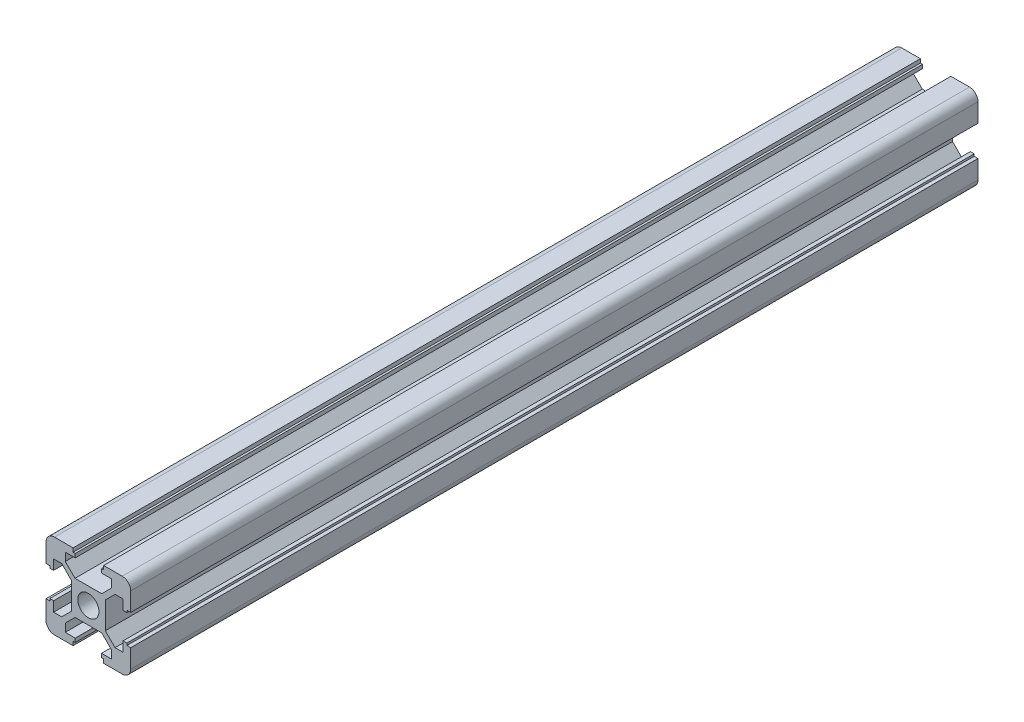
from build123d import *

# Parameters (mm, degrees)
SKETCH_1_R      = 2.5
EXTRUDE_1_DEPTH = 200
FILLET_1_R      = 2


with BuildPart() as part:
    # 草图1 → 凸台-拉伸1 (new body)
    with BuildSketch(Plane.XY):
        Polygon((-3.151471863, 4), (3.151471863, 4), (5.45, 6.298528137), (5.45, 8.2), (3.1, 8.2), (3.1, 9.1), (3.6, 9.1), (3.6, 10), (10, 10), (10, 3.6), (9.1, 3.6), (9.1, 3.1), (8.2, 3.1), (8.2, 5.45), (6.298528137, 5.45), (4, 3.151471863), (4, -3.151471863), (6.298528137, -5.45), (8.2, -5.45), (8.2, -3.1), (9.1, -3.1), (9.1, -3.6), (10, -3.6), (10, -10), (3.6, -10), (3.6, -9.1), (3.1, -9.1), (3.1, -8.2), (5.45, -8.2), (5.45, -6.298528137), (3.151471863, -4), (-3.151471863, -4), (-5.45, -6.298528137), (-5.45, -8.2), (-3.1, -8.2), (-3.1, -9.1), (-3.6, -9.1), (-3.6, -10), (-10, -10), (-10, -3.6), (-9.1, -3.6), (-9.1, -3.1), (-8.2, -3.1), (-8.2, -5.45), (-6.298528137, -5.45), (-4, -3.151471863), (-4, 3.151471863), (-6.298528137, 5.45), (-8.2, 5.45), (-8.2, 3.1), (-9.1, 3.1), (-9.1, 3.6), (-10, 3.6), (-10, 10), (-3.6, 10), (-3.6, 9.1), (-3.1, 9.1), (-3.1, 8.2), (-5.45, 8.2), (-5.45, 6.298528137), align=None)
        Circle(SKETCH_1_R, mode=Mode.SUBTRACT)
    extrude(amount=EXTRUDE_1_DEPTH)

    # 圆角1
    fillet_1_edges = [part.edges().sort_by_distance(p)[0] for p in [
        (10, -10, 100),
        (-10, -10, 100),
        (-10, 10, 100),
        (10, 10, 100),
    ]]
    fillet(fillet_1_edges, radius=FILLET_1_R)


solid = part.part
